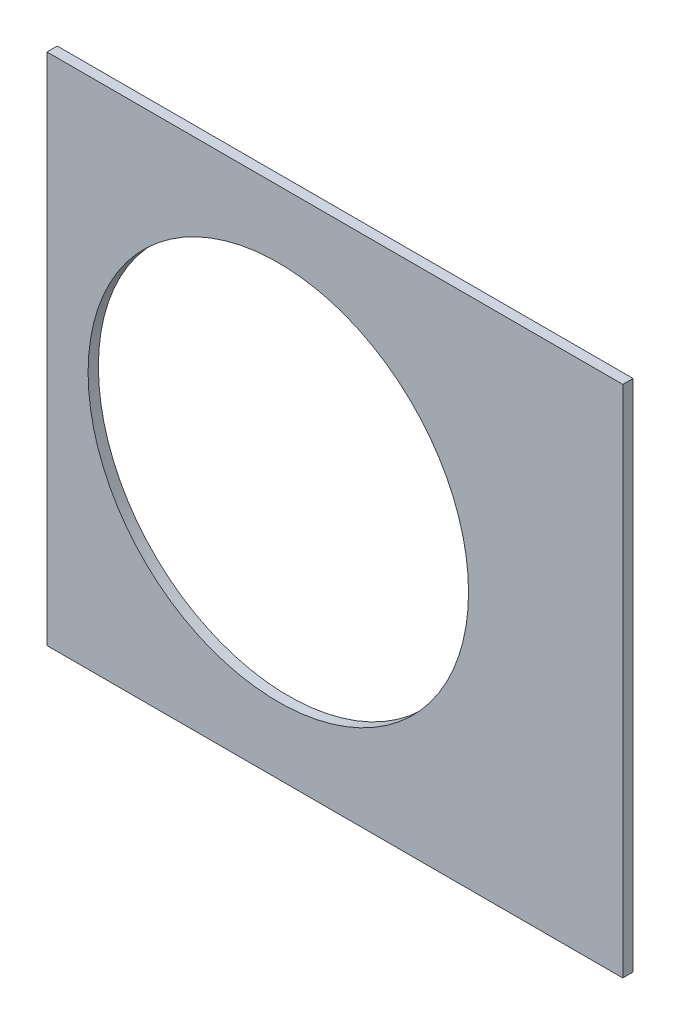
from build123d import *

# Parameters (mm, degrees)
BOSS_EXTRUDE1_DEPTH = 0.254
SKETCH2_R           = 4.699
CUT_EXTRUDE1_DEPTH  = 1.254
SKETCH3_W           = 2.54
SKETCH3_H           = 0.635
CUT_EXTRUDE2_DEPTH  = 1.254
SKETCH5_OUTSIDE_W   = 121.447
SKETCH5_OUTSIDE_H   = 109.618
SKETCH5_OUTSIDE_W_2 = 14.224
SKETCH5_OUTSIDE_H_2 = 15.24
CUT_EXTRUDE5_DEPTH  = 1.254


with BuildPart() as part:
    # Sketch1 → Boss-Extrude1 (new body)
    with BuildSketch(Plane.XY):
        with BuildLine():
            Line((67.21146711, 76.191723231), (8.696654013, 17.676910134))
            Line((8.696654013, 17.676910134), (7.228954972, 14.133571205))
            ThreePointArc((7.228954972, 14.133571205), (14.666587579, 6.075099489), (15.105587123, -4.88230096))
            Line((15.105587123, -4.88230096), (18.648926052, -6.35))
            Line((18.648926052, -6.35), (101.401368334, -6.35))
            ThreePointArc((101.401368334, -6.35), (93.866160503, 38.880636728), (67.21146711, 76.191723231))
        make_face()
        with BuildLine():
            Line((88.672924278, 6.35), (27.86051193, 6.35))
            ThreePointArc((27.86051193, 6.35), (26.399857642, 10.93517908), (24.190484974, 15.210228852))
            Line((24.190484974, 15.210228852), (67.191354125, 58.211098004))
            ThreePointArc((67.191354125, 58.211098004), (82.13289044, 34.020557137), (88.672924278, 6.35))
        make_face(mode=Mode.SUBTRACT)
    extrude(amount=BOSS_EXTRUDE1_DEPTH)

    # Sketch2 → Cut-Extrude1 (cut, through all)
    with BuildSketch(Plane.XY.offset(0.254)):
        with Locations((22.225, 0)):
            Circle(SKETCH2_R)
        with Locations((36.195, 0)):
            Circle(SKETCH2_R)
        with Locations((61.722, 0)):
            Circle(SKETCH2_R)
        with Locations((75.692, 0)):
            Circle(SKETCH2_R)
        with Locations((95.25, 0)):
            Circle(SKETCH2_R)
        with Locations((15.715448212, 15.715448212)):
            Circle(SKETCH2_R)
        with Locations((25.593729945, 25.593729945)):
            Circle(SKETCH2_R)
        with Locations((43.644044748, 43.644044748)):
            Circle(SKETCH2_R)
        with Locations((53.522326482, 53.522326482)):
            Circle(SKETCH2_R)
        with Locations((92.004434954, 24.652514046)):
            Circle(SKETCH2_R)
        with Locations((82.48891971, 47.625)):
            Circle(SKETCH2_R)
        with Locations((67.351920908, 67.351920908)):
            Circle(SKETCH2_R)
    extrude(amount=-CUT_EXTRUDE1_DEPTH, mode=Mode.SUBTRACT)

    # Sketch3 → Cut-Extrude2 (cut, through all)
    with BuildSketch(Plane.XY.offset(0.254)):
        Polygon((15.266435406, 24.246691527), (17.06248663, 26.042742751), (17.511499436, 25.593729945), (15.715448212, 23.797678721), align=None)
        Polygon((44.991083167, 53.971339288), (43.195031942, 52.175288063), (43.644044748, 51.726275257), (45.440095973, 53.522326482), align=None)
        with Locations((29.21, -6.0325)):
            Rectangle(SKETCH3_W, SKETCH3_H)
        with Locations((68.707, -6.0325)):
            Rectangle(SKETCH3_W, SKETCH3_H)
        Polygon((29.230733674, 38.210989795), (31.026784898, 40.007041019), (31.475797704, 39.558028213), (29.67974648, 37.761976989), align=None)
        Polygon((56.845021246, 65.825277367), (55.048970022, 64.029226143), (55.497982828, 63.580213337), (57.294034052, 65.376264561), align=None)
        with Locations((48.9585, -6.0325)):
            Rectangle(SKETCH3_W, SKETCH3_H)
        with Locations((85.471, -6.0325)):
            Rectangle(SKETCH3_W, SKETCH3_H)
        Polygon((99.935462164, 14.437711971), (100.266998693, 11.919442024), (101.526133667, 12.085210288), (101.194597138, 14.603480236), align=None)
        Polygon((93.765504959, 37.464305742), (94.938831965, 37.950313702), (93.966816047, 40.296967714), (92.793489041, 39.810959755), align=None)
        Polygon((79.327792988, 62.471156422), (80.874047017, 60.456038938), (81.88160576, 61.229165953), (80.33535173, 63.244283437), align=None)
        Polygon((13.593916116, 7.005422516), (14.565932035, 4.658768503), (15.739259041, 5.144776462), (14.767243123, 7.491430475), align=None)
    extrude(amount=-CUT_EXTRUDE2_DEPTH, mode=Mode.SUBTRACT)

    # Sketch5 outside → Cut-Extrude5 (cut, through all)
    with BuildSketch(Plane.XY.offset(0.254)):
        with Locations((54.4145, 34.921)):
            Rectangle(SKETCH5_OUTSIDE_W, SKETCH5_OUTSIDE_H)
        with Locations((77.089, 0)):
            Rectangle(SKETCH5_OUTSIDE_W_2, SKETCH5_OUTSIDE_H_2, mode=Mode.SUBTRACT)
    extrude(amount=-CUT_EXTRUDE5_DEPTH, mode=Mode.SUBTRACT)


solid = part.part
